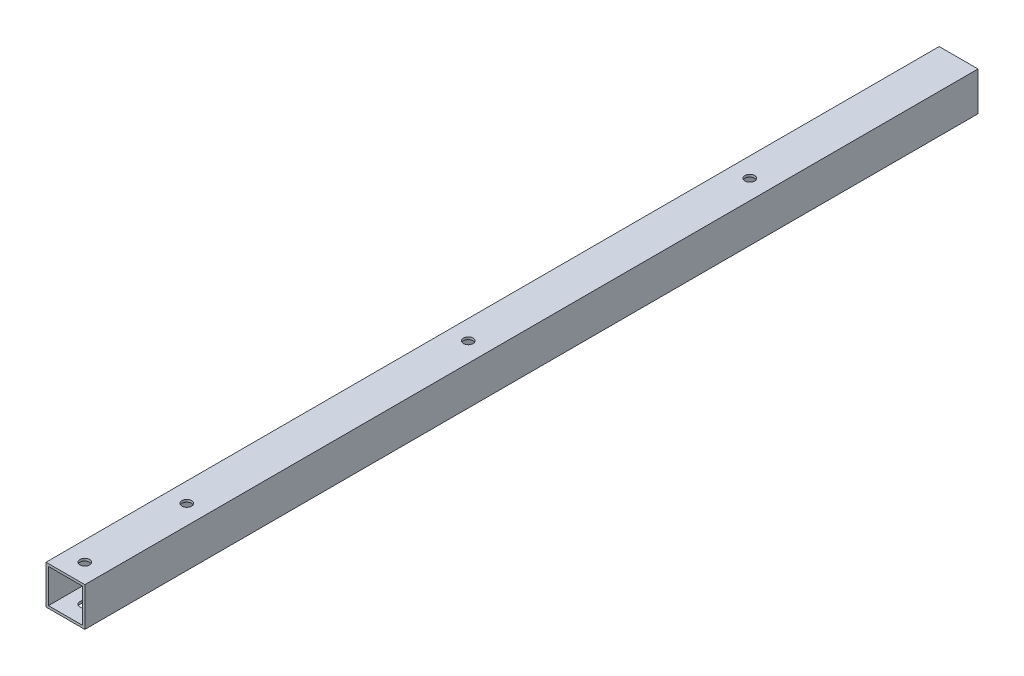
from build123d import *

# Parameters (mm, degrees)
SKETCH1_W           = 50.8
SKETCH1_H           = 50.8
SKETCH1_W_2         = 44.45
SKETCH1_H_2         = 44.45
EXTRUDE1_DEPTH      = 1117.6
EXTRUDE1_DEPTH_BACK = 50.8
SKETCH3_R           = 6.35
CUT_EXTRUDE2_DEPTH  = 51.8


with BuildPart() as part:
    # Sketch1 → Extrude1 (new body, two sides)
    with BuildSketch(Plane.XY) as extrude1_sk:
        with Locations((-514.35, 304.8)):
            Rectangle(SKETCH1_W, SKETCH1_H)
        with Locations((-514.35, 304.8)):
            Rectangle(SKETCH1_W_2, SKETCH1_H_2, mode=Mode.SUBTRACT)
    extrude(amount=EXTRUDE1_DEPTH)
    extrude(extrude1_sk.sketch, amount=-EXTRUDE1_DEPTH_BACK)

    # Sketch3 → Cut-Extrude2 (cut, through all)
    with BuildSketch(Plane(origin=(0, 330.2, 0), x_dir=(1, 0, 0), z_dir=(0, 1, 0))):
        with Locations((-514.35, -1092.2)):
            Circle(SKETCH3_R)
        with Locations((-514.35, -958.85)):
            Circle(SKETCH3_R)
        with Locations((-514.35, -590.55)):
            Circle(SKETCH3_R)
        with Locations((-514.35, -222.25)):
            Circle(SKETCH3_R)
    extrude(amount=-CUT_EXTRUDE2_DEPTH, mode=Mode.SUBTRACT)


solid = part.part
